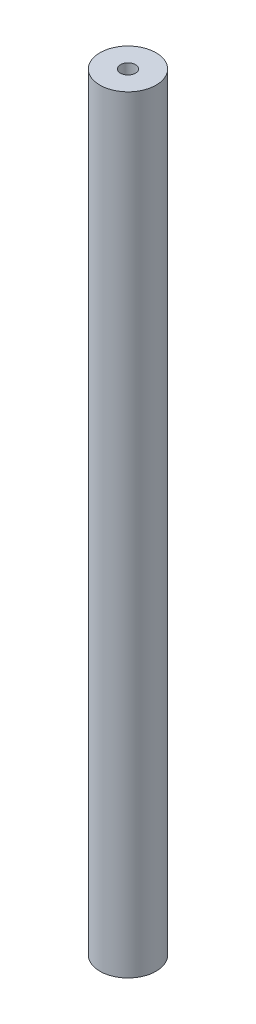
from build123d import *

# Parameters (mm, degrees)
SKETCH1_R           = 7.5
BOSS_EXTRUDE1_DEPTH = 102.5
SKETCH2_R           = 2
CUT_EXTRUDE1_DEPTH  = 15


with BuildPart() as part:
    # Sketch1 → Boss-Extrude1 (new body, symmetric)
    with BuildSketch(Plane(origin=(0, 0, 0), x_dir=(1, 0, 0), z_dir=(0, 1, 0))):
        Circle(SKETCH1_R)
    extrude(amount=BOSS_EXTRUDE1_DEPTH, both=True)

    # Sketch2 → Cut-Extrude1 (cut)
    with BuildSketch(Plane(origin=(0, 102.5, 0), x_dir=(1, 0, 0), z_dir=(0, 1, 0))):
        Circle(SKETCH2_R)
    extrude(amount=-CUT_EXTRUDE1_DEPTH, mode=Mode.SUBTRACT)


solid = part.part
